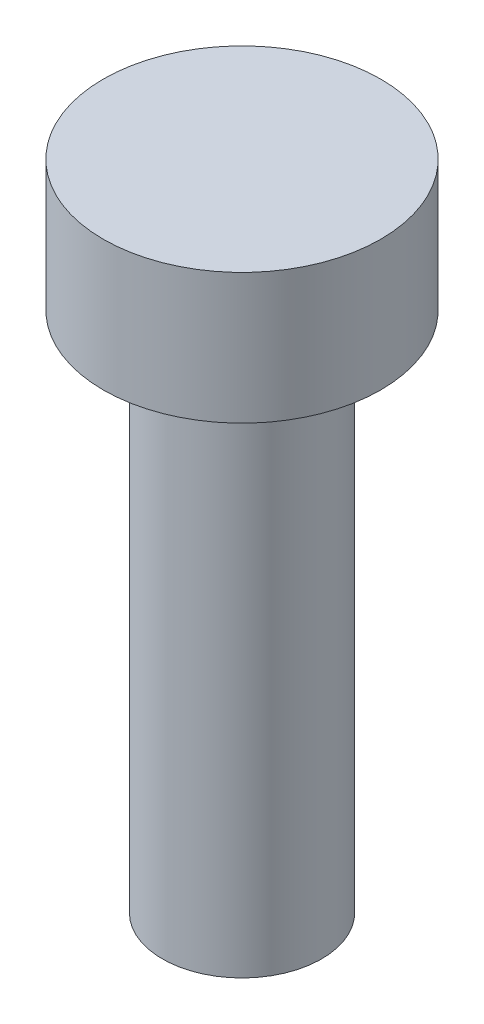
from build123d import *

# Parameters (mm, degrees)
SKETCH1_R           = 4.25
BOSS_EXTRUDE1_DEPTH = 4
SKETCH2_R           = 2.44
BOSS_EXTRUDE2_DEPTH = 16


with BuildPart() as part:
    # Sketch1 → Boss-Extrude1 (new body)
    with BuildSketch(Plane(origin=(0, 0, 0), x_dir=(1, 0, 0), z_dir=(0, 1, 0))):
        Circle(SKETCH1_R)
    extrude(amount=BOSS_EXTRUDE1_DEPTH)

    # Sketch2 → Boss-Extrude2 (add)
    with BuildSketch(Plane.XZ):
        Circle(SKETCH2_R)
    extrude(amount=BOSS_EXTRUDE2_DEPTH)


solid = part.part
